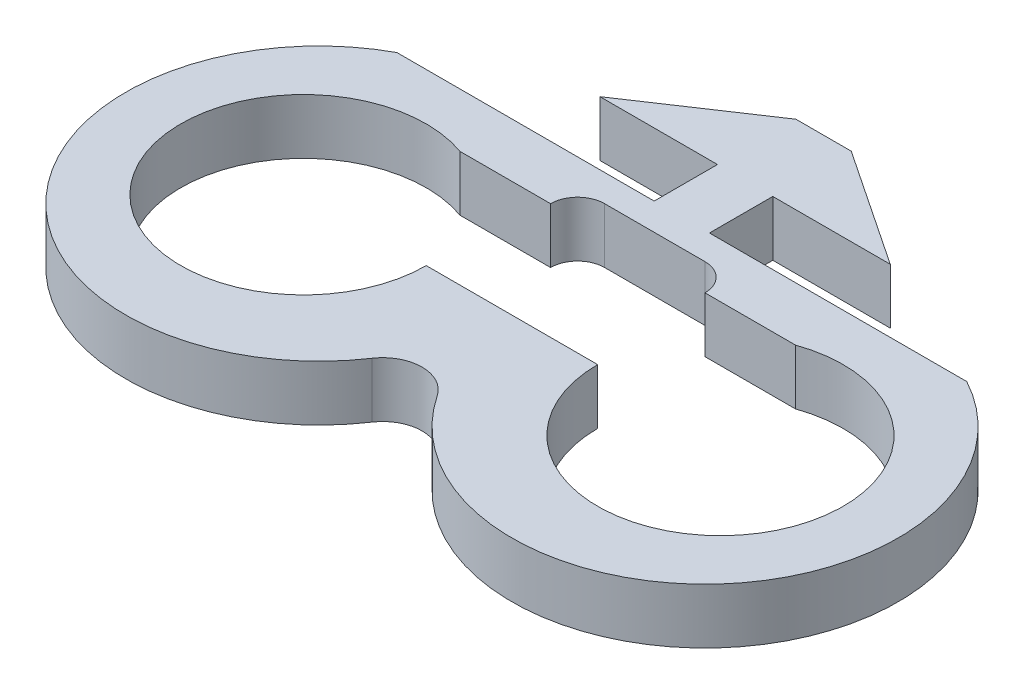
from build123d import *

# Parameters (mm, degrees)
BOSS_EXTRUDE1_DEPTH = 3.5814
BOSS_EXTRUDE2_DEPTH = 3.5814
SKETCH4_R           = 7.95
CUT_EXTRUDE2_DEPTH  = 4.5814
CUT_EXTRUDE4_REACH  = 5.581
CUT_EXTRUDE5_REACH  = 5.581


with BuildPart() as part:
    # Sketch1 → Boss-Extrude1 (new body)
    with BuildSketch(Plane(origin=(0, 0, 0), x_dir=(1, 0, 0), z_dir=(0, 1, 0))):
        Polygon((-25.0063, -13.0482), (25.0063, -13.0482), (25.0063, -2.05), (1.7907, -2.05), (1.7907, 2.05), (9.398, 2.05), (1.7907, 7.13), (-1.7907, 7.13), (-9.398, 2.05), (-1.7907, 2.05), (-1.7907, -2.05), (-25.0063, -2.05), align=None)
    extrude(amount=BOSS_EXTRUDE1_DEPTH)

    # Sketch3 → Boss-Extrude2 (add)
    with BuildSketch(Plane(origin=(0, 3.5814, 0), x_dir=(1, 0, 0), z_dir=(0, 1, 0))):
        Polygon((-25.0063, -2.05), (-25.0063, -13.0482), (25.0063, -13.0482), (25.0063, -2.05), (1.7907, -2.05), (1.7907, 2.05), (9.398, 2.05), (1.7907, 7.13), (-1.7907, 7.13), (-9.398, 2.05), (-1.7907, 2.05), (-1.7907, -2.05), align=None)
        with BuildLine():
            Line((25.0063, -13.0482), (-25.0063, -13.0482))
            ThreePointArc((-25.0063, -13.0482), (-16.136037163, -25.01193231), (-2.111127058, -20.000510342))
            ThreePointArc((-2.111127058, -20.000510342), (0, -18.87286389), (2.111127058, -20.000510342))
            ThreePointArc((2.111127058, -20.000510342), (16.136037163, -25.01193231), (25.0063, -13.0482))
        make_face()
    extrude(amount=-BOSS_EXTRUDE2_DEPTH)

    # Sketch4 → Cut-Extrude2 (cut, through all)
    with BuildSketch(Plane(origin=(0, 3.5814, 0), x_dir=(1, 0, 0), z_dir=(0, 1, 0))):
        with Locations((-13.5, -13.0482)):
            Circle(SKETCH4_R)
        with Locations((13.5, -13.0482)):
            Circle(SKETCH4_R)
    extrude(amount=-CUT_EXTRUDE2_DEPTH, mode=Mode.SUBTRACT)

    # Sketch5 → Cut-Extrude4 (cut, up to next)
    with BuildSketch(Plane(origin=(0, 3.5814, 0), x_dir=(1, 0, 0), z_dir=(0, 1, 0)), mode=Mode.PRIVATE) as cut_extrude4_sk1:
        with BuildLine():
            Line((-3.25, -3.8), (3.25, -3.8))
            ThreePointArc((3.25, -3.8), (4.487436867, -4.312563133), (5, -5.55))
            Line((5, -5.55), (10.858126279, -5.55))
            ThreePointArc((10.858126279, -5.55), (7.011340813, -8.454747926), (5.55, -13.0482))
            Line((5.55, -13.0482), (-5.55, -13.0482))
            ThreePointArc((-5.55, -13.0482), (-7.011340813, -8.454747926), (-10.858126279, -5.55))
            Line((-10.858126279, -5.55), (-5, -5.55))
            ThreePointArc((-5, -5.55), (-4.487436867, -4.312563133), (-3.25, -3.8))
        make_face()
    cut_extrude4_tool1 = extrude(cut_extrude4_sk1.sketch, amount=-CUT_EXTRUDE4_REACH, mode=Mode.PRIVATE) & part.part
    add(cut_extrude4_tool1.solids().sort_by_distance((0, 3.5814, 8.325803))[0], mode=Mode.SUBTRACT)

    # Sketch6 → Cut-Extrude5 (cut, up to next)
    with BuildSketch(Plane(origin=(0, 3.5814, 0), x_dir=(1, 0, 0), z_dir=(0, 1, 0)), mode=Mode.PRIVATE) as cut_extrude5_sk1:
        with BuildLine():
            Line((-18.450280122, -2.05), (-25.0063, -2.05))
            Line((-25.0063, -2.05), (-25.0063, -13.0482))
            ThreePointArc((-25.0063, -13.0482), (-23.242950275, -6.64621203), (-18.450280122, -2.05))
        make_face()
    cut_extrude5_tool1 = extrude(cut_extrude5_sk1.sketch, amount=-CUT_EXTRUDE5_REACH, mode=Mode.PRIVATE) & part.part
    add(cut_extrude5_tool1.solids().sort_by_distance((-23.17616, 3.5814, 4.635288))[0], mode=Mode.SUBTRACT)
    # Sketch6 → Cut-Extrude5 (cut, up to next)
    with BuildSketch(Plane(origin=(0, 3.5814, 0), x_dir=(1, 0, 0), z_dir=(0, 1, 0)), mode=Mode.PRIVATE) as cut_extrude5_sk2:
        with BuildLine():
            Line((25.0063, -13.0482), (25.0063, -2.05))
            Line((25.0063, -2.05), (18.450280122, -2.05))
            ThreePointArc((18.450280122, -2.05), (23.242950275, -6.64621203), (25.0063, -13.0482))
        make_face()
    cut_extrude5_tool2 = extrude(cut_extrude5_sk2.sketch, amount=-CUT_EXTRUDE5_REACH, mode=Mode.PRIVATE) & part.part
    add(cut_extrude5_tool2.solids().sort_by_distance((23.17616, 3.5814, 4.635288))[0], mode=Mode.SUBTRACT)


solid = part.part
